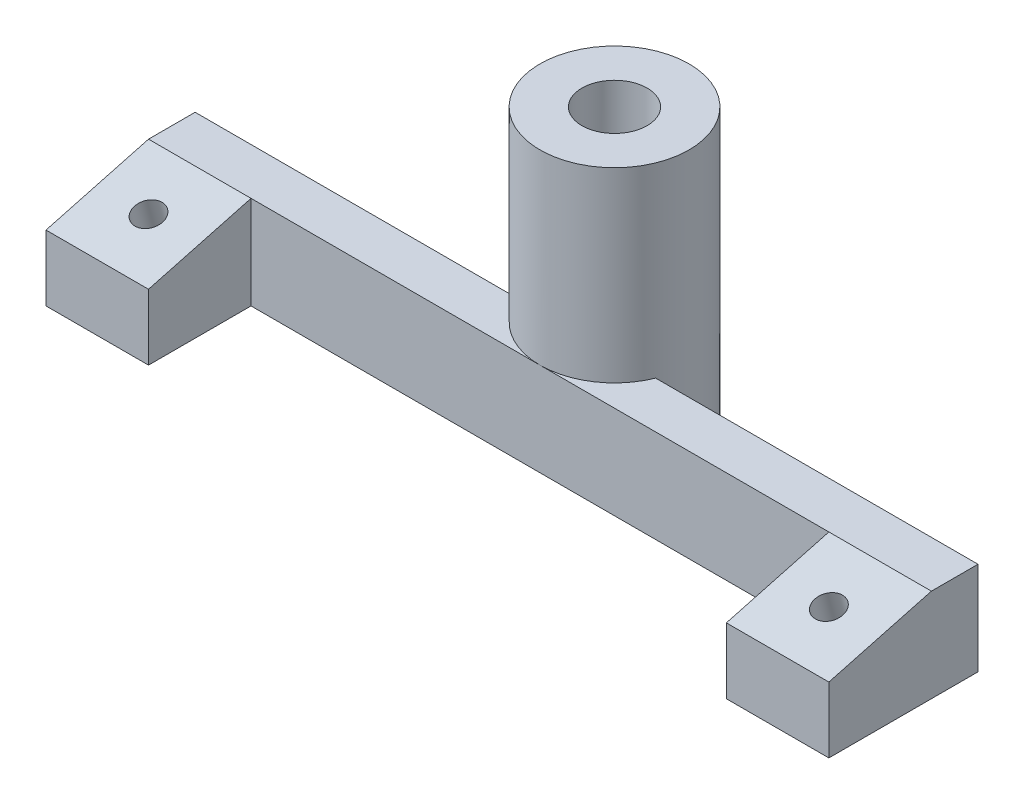
from build123d import *

# Parameters (mm, degrees)
EXTRUDE_1_DEPTH     = 10
CUT_EXTRUDE_4_DEPTH = 85
SKETCH_6_R          = 1.5
CUT_EXTRUDE_5_DEPTH = 11.953353488
SKETCH_7_R          = 3.25
CUT_EXTRUDE_6_DEPTH = 7.953353488
SKETCH_8_R          = 8
EXTRUDE_2_DEPTH     = 30
SKETCH_9_R          = 3.5
CUT_EXTRUDE_7_DEPTH = 30
SKETCH_10_R         = 5.25
CUT_EXTRUDE_8_DEPTH = 24


with BuildPart() as part:
    # 草图1 → 凸台-拉伸1 (new body)
    with BuildSketch(Plane(origin=(0, 0, 0), x_dir=(1, 0, 0), z_dir=(0, 1, 0))):
        Polygon((-42, 5.5), (-42, 10.5), (42, 10.5), (42, 5.5), (42, -5.5), (31, -5.5), (31, 5.5), (-31, 5.5), (-31, -5.5), (-42, -5.5), align=None)
    extrude(amount=EXTRUDE_1_DEPTH)

    # 草图5 → 切除-拉伸4 (cut, through all)
    with BuildSketch(Plane.ZY.offset(42)):
        Polygon((-5.5, 10), (5.5, 7.052558883), (5.5, 10), align=None)
    extrude(amount=-CUT_EXTRUDE_4_DEPTH, mode=Mode.SUBTRACT)

    # 草图6 → 切除-拉伸5 (cut, through all)
    with BuildSketch(Plane(origin=(0, 12.383949988, -14.397022476), x_dir=(1, 0, 0), z_dir=(0, -0.965925826, -0.258819045))):
        with Locations((-36.5, 14.904894438)):
            Circle(SKETCH_6_R)
        with Locations((36.5, 14.904894438)):
            Circle(SKETCH_6_R)
    extrude(amount=CUT_EXTRUDE_5_DEPTH, mode=Mode.SUBTRACT)

    # 草图7 → 切除-拉伸6 (cut, through all)
    with BuildSketch(Plane(origin=(0, 4.091423714, 1.09629368), x_dir=(1, 0, 0), z_dir=(0, 0.965925826, 0.258819045))):
        with Locations((-36.5, 2.206763503)):
            Circle(SKETCH_7_R)
        with Locations((36.5, 2.206763503)):
            Circle(SKETCH_7_R)
    extrude(amount=-CUT_EXTRUDE_6_DEPTH, mode=Mode.SUBTRACT)

    # 草图8 → 凸台-拉伸2 (add)
    with BuildSketch(Plane.XZ):
        with Locations((0, -13.5)):
            Circle(SKETCH_8_R)
    extrude(amount=-EXTRUDE_2_DEPTH)

    # 草图9 → 切除-拉伸7 (cut)
    with BuildSketch(Plane(origin=(0, 30, 0), x_dir=(1, 0, 0), z_dir=(0, 1, 0))):
        with Locations((0, 13.5)):
            Circle(SKETCH_9_R)
    extrude(amount=-CUT_EXTRUDE_7_DEPTH, mode=Mode.SUBTRACT)

    # 草图10 → 切除-拉伸8 (cut)
    with BuildSketch(Plane.XZ):
        with Locations((0, -13.5)):
            Circle(SKETCH_10_R)
    extrude(amount=-CUT_EXTRUDE_8_DEPTH, mode=Mode.SUBTRACT)


solid = part.part
